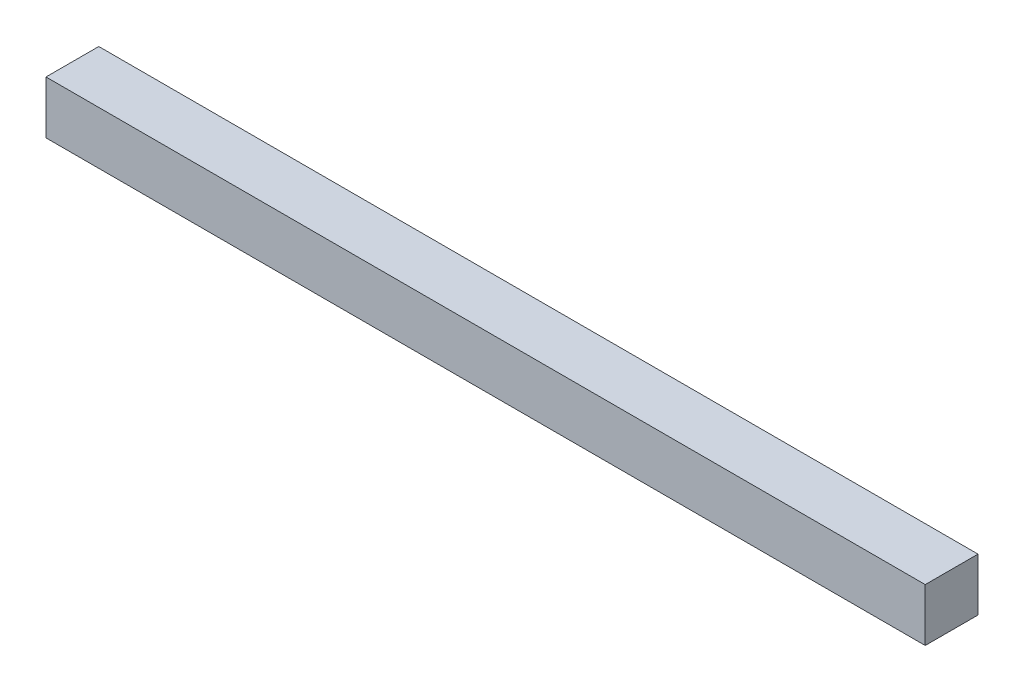
from build123d import *

# Parameters (mm, degrees)
SKETCH1_W           = 25.4
SKETCH1_H           = 25.4
BOSS_EXTRUDE1_DEPTH = 423.164


with BuildPart() as part:
    # Sketch1 → Boss-Extrude1 (new body)
    with BuildSketch(Plane(origin=(0, 0, 0), x_dir=(0, 0, -1), z_dir=(1, 0, 0))):
        with Locations((12.7, 12.7)):
            Rectangle(SKETCH1_W, SKETCH1_H)
    extrude(amount=BOSS_EXTRUDE1_DEPTH)


solid = part.part
